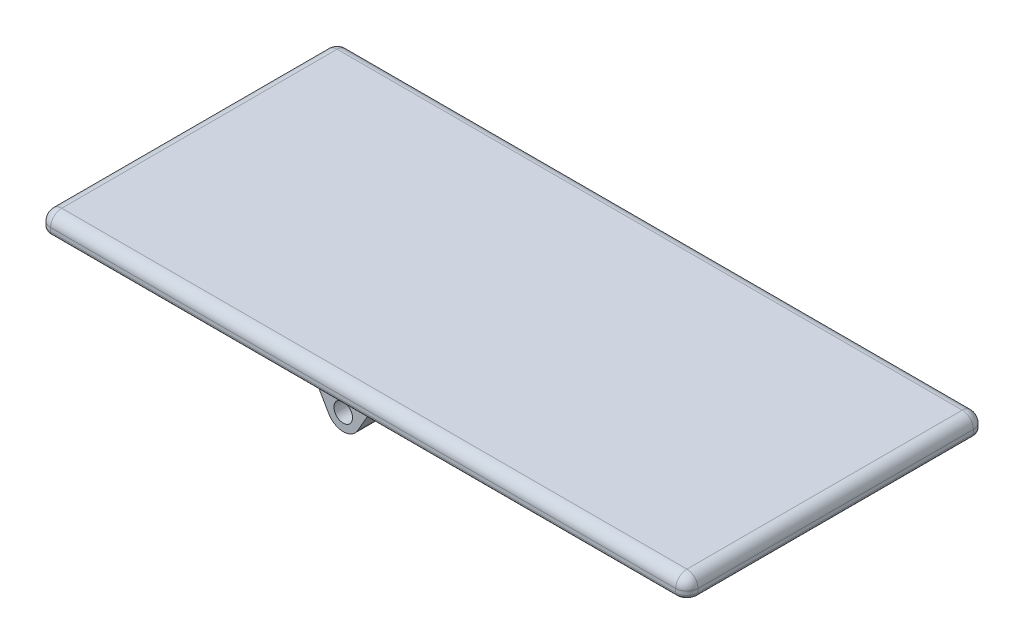
from build123d import *

# Parameters (mm, degrees)
BOSS_EXTRUDE3_DEPTH = 80
BOSS_EXTRUDE2_START = -5.3
SKETCH2_R           = 2.5
BOSS_EXTRUDE2_DEPTH = 5
LPATTERN1_COUNT     = 3
LPATTERN1_PITCH     = 32.2
FILLET1_R           = 3
FILLET2_R           = 1


with BuildPart() as part:
    # Sketch3 → Boss-Extrude3 (new body)
    with BuildSketch(Plane.XY):
        Polygon((97.654693799, 0), (97.654693799, 5), (-76.347854423, 5), (-76.347854423, 0), (0, 0), align=None)
    extrude(amount=BOSS_EXTRUDE3_DEPTH)

    # Sketch2 → Boss-Extrude2 (add)
    with BuildSketch(Plane(origin=(0, 0, 0), x_dir=(-1, 0, 0), z_dir=(0, 0, -1)).offset(BOSS_EXTRUDE2_START)):
        with BuildLine():
            Line((-3.897114317, -9.25), (-9.237604307, 0))
            Line((-9.237604307, 0), (9.237604307, 0))
            Line((9.237604307, 0), (3.897114317, -9.25))
            ThreePointArc((3.897114317, -9.25), (0, -11.5), (-3.897114317, -9.25))
        make_face()
        with Locations((0, -7)):
            Circle(SKETCH2_R, mode=Mode.SUBTRACT)
    boss_extrude2 = extrude(amount=-BOSS_EXTRUDE2_DEPTH)

    # LPattern1: Boss-Extrude2 ×3
    with Locations(*[(0, 0, i * LPATTERN1_PITCH) for i in range(1, LPATTERN1_COUNT)]):
        add(boss_extrude2)

    # Fillet1
    fillet1_edges = [part.edges().sort_by_distance(p)[0] for p in [
        (10.653419688, 5, 80),
        (-76.347854423, 2.5, 80),
        (-76.347854423, 2.5, 0),
        (10.653419688, 5, 0),
        (97.654693799, 2.5, 0),
        (97.654693799, 2.5, 80),
        (-76.347854423, 5, 40),
        (97.654693799, 5, 40),
    ]]
    fillet(fillet1_edges, radius=FILLET1_R)

    # Fillet2
    fillet2_edges = [part.edges().sort_by_distance(p)[0] for p in [
        (97.654693799, 0, 40),
        (10.653419688, 0, 0),
        (-76.347854423, 0, 40),
        (10.653419688, 0, 80),
        (96.776014142, 0, 0.878679656),
        (-75.469174766, 0, 0.878679656),
        (-75.469174766, 0, 79.121320344),
        (96.776014142, 0, 79.121320344),
    ]]
    fillet(fillet2_edges, radius=FILLET2_R)


solid = part.part
